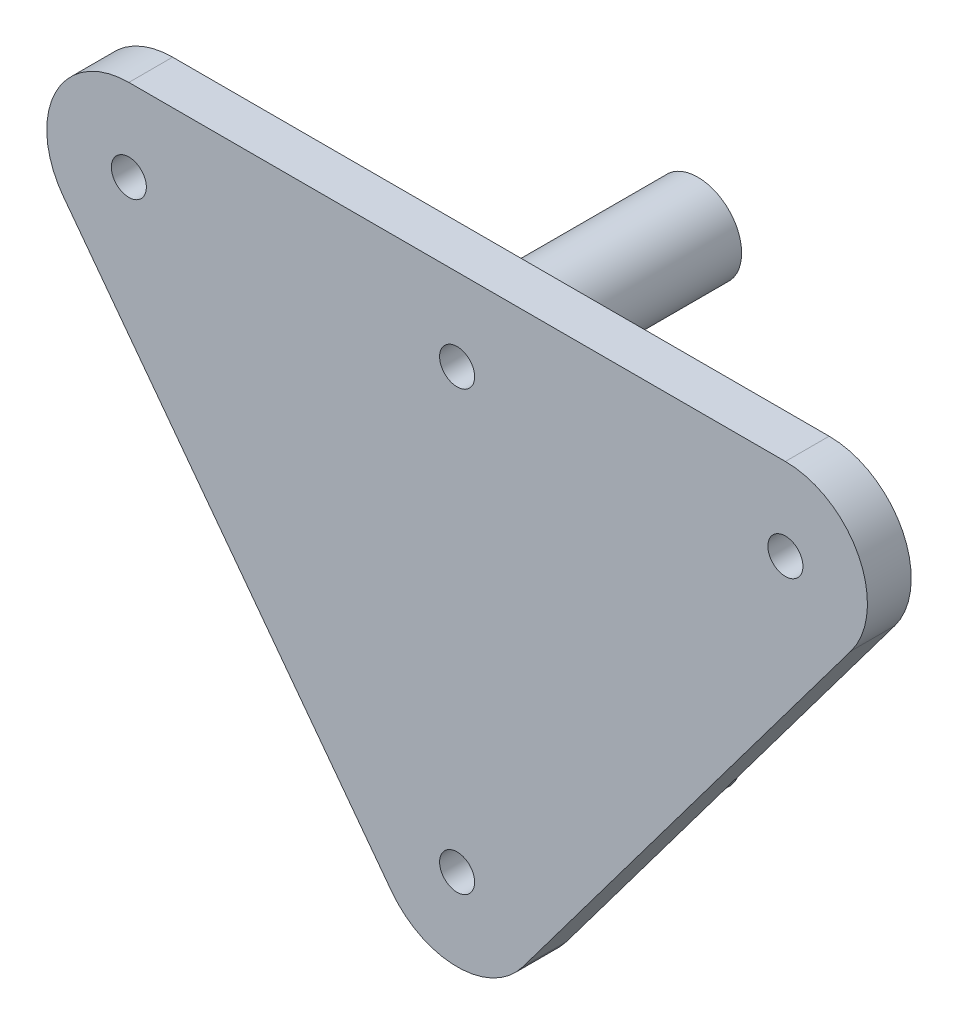
from build123d import *

# Parameters (mm, degrees)
SKETCH1_R           = 1.6
BOSS_EXTRUDE1_DEPTH = 4
SKETCH1_4_R         = 4
SKETCH1_4_R_2       = 1.6
BOSS_EXTRUDE2_DEPTH = 18
SKETCH3_R           = 3.6
SKETCH3_R_2         = 1.6
BOSS_EXTRUDE3_DEPTH = 0.5
FILLET1_R           = 2


with BuildPart() as part:
    # Sketch1 → Boss-Extrude1 (new body)
    with BuildSketch(Plane.XY):
        with BuildLine():
            Line((-36, 15.5), (-6, -24.5))
            ThreePointArc((-6, -24.5), (0, -27.5), (6, -24.5))
            Line((6, -24.5), (36, 15.5))
            ThreePointArc((36, 15.5), (36.708203932, 23.354101966), (30, 27.5))
            Line((30, 27.5), (-30, 27.5))
            ThreePointArc((-30, 27.5), (-36.708203932, 23.354101966), (-36, 15.5))
        make_face()
        with Locations((-30, 20)):
            Circle(SKETCH1_R, mode=Mode.SUBTRACT)
        with Locations((30, 20)):
            Circle(SKETCH1_R, mode=Mode.SUBTRACT)
        with Locations((0, 20)):
            Circle(SKETCH1_R, mode=Mode.SUBTRACT)
        with Locations((0, -20)):
            Circle(SKETCH1_R, mode=Mode.SUBTRACT)
    extrude(amount=BOSS_EXTRUDE1_DEPTH)

    # Sketch1_4 → Boss-Extrude2 (add)
    with BuildSketch(Plane.XY):
        with Locations((0, 20)):
            Circle(SKETCH1_4_R)
        with Locations((0, 20)):
            Circle(SKETCH1_4_R_2, mode=Mode.SUBTRACT)
        with Locations((0, -20)):
            Circle(SKETCH1_4_R)
        with Locations((0, -20)):
            Circle(SKETCH1_4_R_2, mode=Mode.SUBTRACT)
    extrude(amount=-BOSS_EXTRUDE2_DEPTH)

    # Sketch3 → Boss-Extrude3 (add)
    with BuildSketch(Plane(origin=(0, 0, 0), x_dir=(-1, 0, 0), z_dir=(0, 0, -1))):
        with Locations((-30, 20)):
            Circle(SKETCH3_R)
        with Locations((-30, 20)):
            Circle(SKETCH3_R_2, mode=Mode.SUBTRACT)
        with Locations((30, 20)):
            Circle(SKETCH3_R)
        with Locations((30, 20)):
            Circle(SKETCH3_R_2, mode=Mode.SUBTRACT)
    extrude(amount=BOSS_EXTRUDE3_DEPTH)

    # Fillet1
    fillet1_edges = [part.edges().sort_by_distance(p)[0] for p in [
        (-4, 20, 0),
        (-4, -20, 0),
    ]]
    fillet(fillet1_edges, radius=FILLET1_R)


solid = part.part
